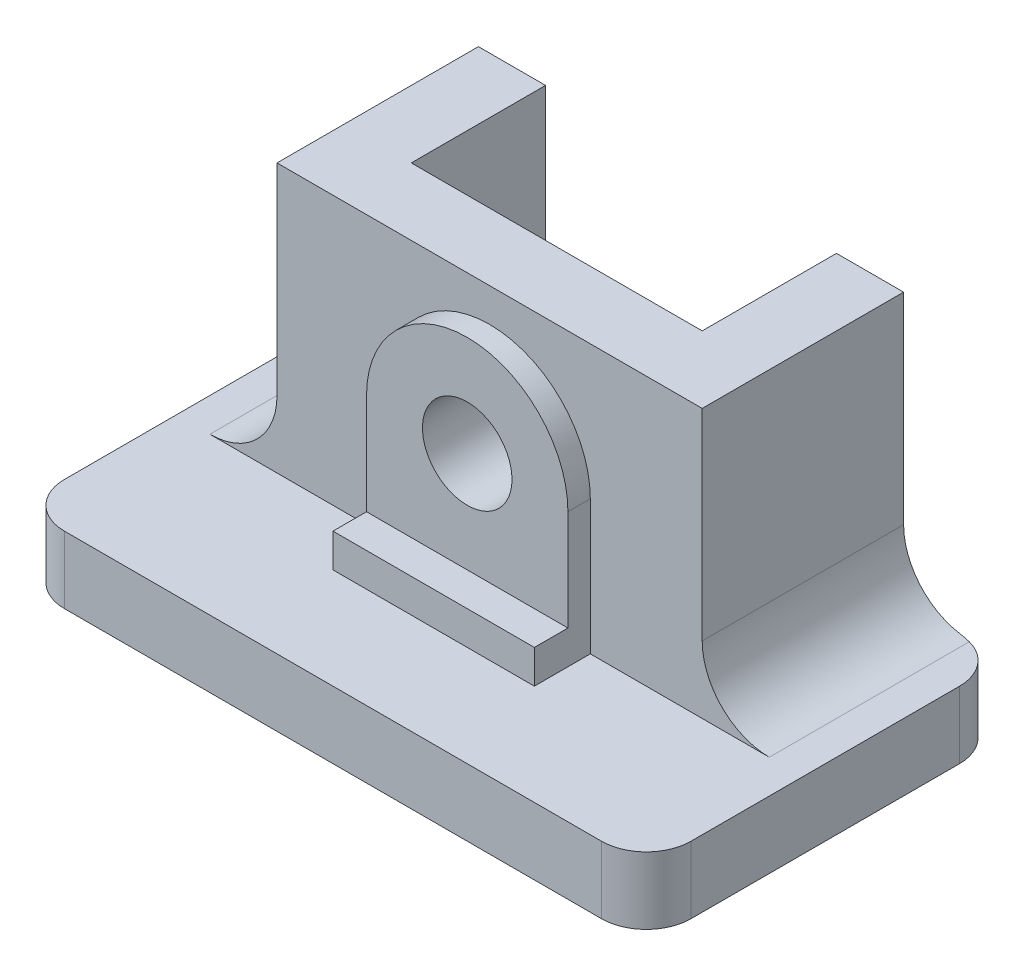
from build123d import *

# Parameters (mm, degrees)
BOSS_EXTRUDE1_DEPTH = 50.8
SKETCH2_W           = 41.275
SKETCH2_H           = 19.05
SKETCH2_W_2         = 88.9
SKETCH2_H_2         = 22.225
CUT_EXTRUDE2_DEPTH  = 48.625
SKETCH3_R           = 6.35
BOSS_EXTRUDE2_DEPTH = 3.175
SKETCH4_W           = 88.9
SKETCH4_H           = 9.525
BOSS_EXTRUDE3_DEPTH = 22.225
SKETCH5_W           = 28.575
SKETCH5_H           = 4.7625
BOSS_EXTRUDE4_DEPTH = 4.7625
FILLET1_R           = 6.35
SKETCH6_R           = 6.35
CUT_EXTRUDE3_DEPTH  = 29.5750001


with BuildPart() as part:
    # Sketch1 → Boss-Extrude1 (new body)
    with BuildSketch(Plane.XY):
        with BuildLine():
            Line((-14.2875, 47.625), (-74.6125, 47.625))
            Line((-74.6125, 47.625), (-74.6125, 19.05))
            ThreePointArc((-74.6125, 19.05), (-77.402307909, 12.314807909), (-84.1375, 9.525))
            Line((-84.1375, 9.525), (-88.9, 9.525))
            Line((-88.9, 9.525), (-88.9, 0))
            Line((-88.9, 0), (0, 0))
            Line((0, 0), (0, 9.525))
            Line((0, 9.525), (-4.7625, 9.525))
            ThreePointArc((-4.7625, 9.525), (-11.497692091, 12.314807909), (-14.2875, 19.05))
            Line((-14.2875, 19.05), (-14.2875, 47.625))
        make_face()
    extrude(amount=BOSS_EXTRUDE1_DEPTH)

    # Sketch2 → Cut-Extrude2 (cut, through all)
    with BuildSketch(Plane(origin=(0, 47.625, 0), x_dir=(1, 0, 0), z_dir=(0, 1, 0))):
        with Locations((-44.45, -9.525)):
            Rectangle(SKETCH2_W, SKETCH2_H)
        with Locations((-44.45, -39.6875)):
            Rectangle(SKETCH2_W_2, SKETCH2_H_2)
    extrude(amount=-CUT_EXTRUDE2_DEPTH, mode=Mode.SUBTRACT)

    # Sketch3 → Boss-Extrude2 (add)
    with BuildSketch(Plane.XY.offset(28.575)):
        with BuildLine():
            Line((-58.7375, 28.575), (-58.7375, 9.525))
            Line((-58.7375, 9.525), (-30.1625, 9.525))
            Line((-30.1625, 9.525), (-30.1625, 28.575))
            ThreePointArc((-30.1625, 28.575), (-44.45, 42.8625), (-58.7375, 28.575))
        make_face()
        with Locations((-44.45, 28.575)):
            Circle(SKETCH3_R, mode=Mode.SUBTRACT)
    extrude(amount=BOSS_EXTRUDE2_DEPTH)

    # Sketch4 → Boss-Extrude3 (add)
    with BuildSketch(Plane.XY.offset(28.575)):
        with Locations((-44.45, 4.7625)):
            Rectangle(SKETCH4_W, SKETCH4_H)
    extrude(amount=BOSS_EXTRUDE3_DEPTH)

    # Sketch5 → Boss-Extrude4 (add)
    with BuildSketch(Plane.XY.offset(31.75)):
        with Locations((-44.45, 11.90625)):
            Rectangle(SKETCH5_W, SKETCH5_H)
    extrude(amount=BOSS_EXTRUDE4_DEPTH)

    # Fillet1
    fillet1_edges = [part.edges().sort_by_distance(p)[0] for p in [
        (-88.9, 4.7625, 0),
        (-88.9, 4.7625, 50.8),
        (0, 4.7625, 50.8),
        (0, 4.7625, 0),
    ]]
    fillet(fillet1_edges, radius=FILLET1_R)

    # Sketch6 → Cut-Extrude3 (cut, through all)
    with BuildSketch(Plane.XY.offset(28.575)):
        with Locations((-44.45, 28.575)):
            Circle(SKETCH6_R)
    extrude(amount=-CUT_EXTRUDE3_DEPTH, mode=Mode.SUBTRACT)


solid = part.part
